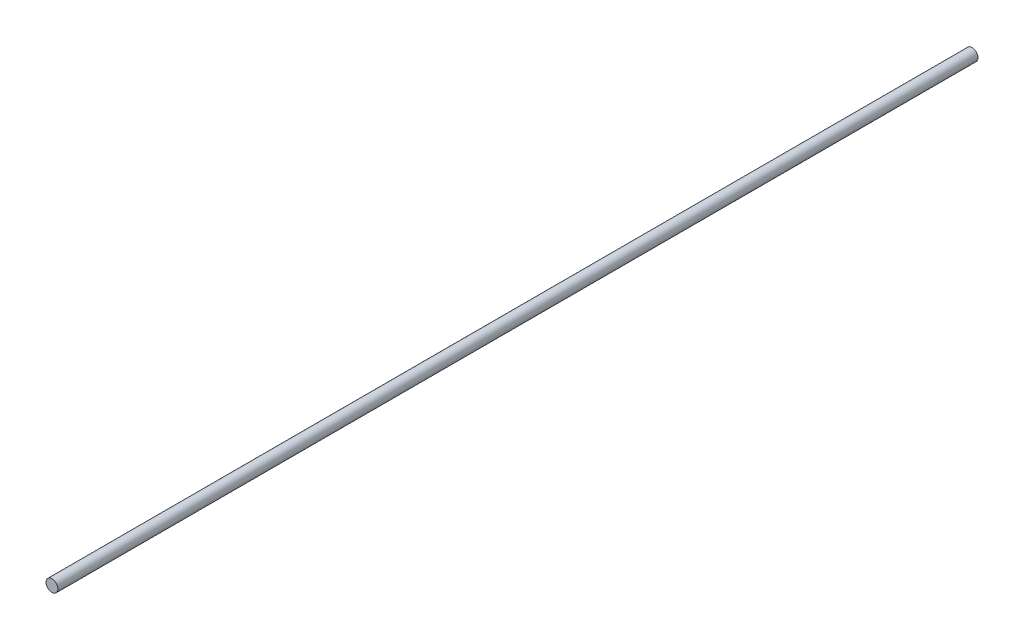
from build123d import *

# Parameters (mm, degrees)
ESQUISSE1_R        = 4
BOSS_EXTRU_1_DEPTH = 620


with BuildPart() as part:
    # Esquisse1 → Boss.-Extru.1 (new body)
    with BuildSketch(Plane.XY):
        Circle(ESQUISSE1_R)
    extrude(amount=BOSS_EXTRU_1_DEPTH)


solid = part.part
